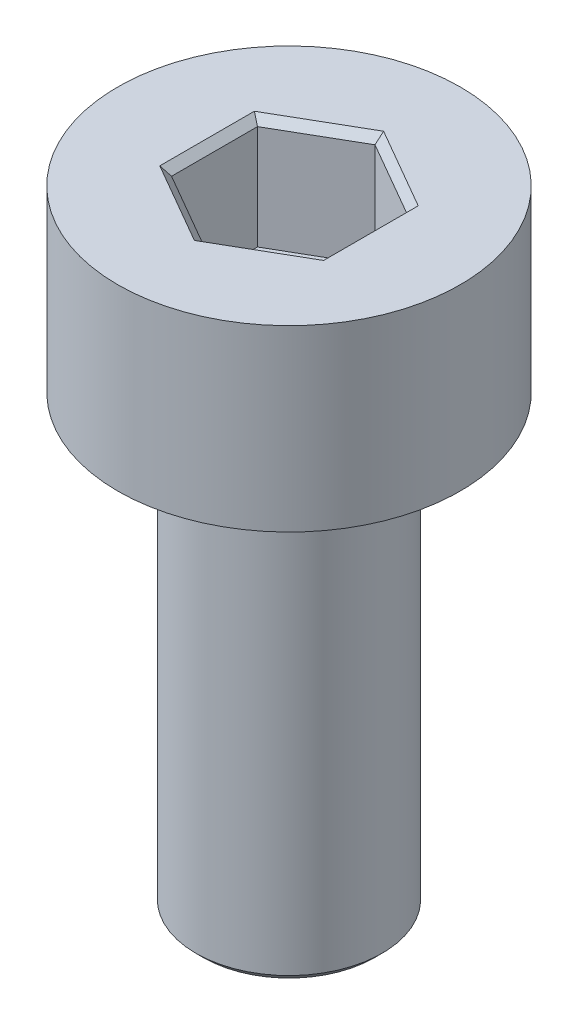
from build123d import *

# Parameters (mm, degrees)
SKETCH_1_R          = 2.3
EXTRUDE_1_DEPTH     = 2.4
CUT_EXTRUDE_1_DEPTH = 1.5
SKETCH_3_R          = 1.25
EXTRUDE_2_DEPTH     = 6
CHAMFER_1_SIZE      = 0.1


with BuildPart() as part:
    # 草图1 → 凸台-拉伸1 (new body)
    with BuildSketch(Plane(origin=(0, 0, 0), x_dir=(1, 0, 0), z_dir=(0, 1, 0))):
        Circle(SKETCH_1_R)
    extrude(amount=EXTRUDE_1_DEPTH)

    # 草图2 → 切除-拉伸1 (cut)
    with BuildSketch(Plane(origin=(0, 2.4, 0), x_dir=(1, 0, 0), z_dir=(0, 1, 0))):
        Polygon((0, -1.154700538), (1, -0.577350269), (1, 0.577350269), (0, 1.154700538), (-1, 0.577350269), (-1, -0.577350269), align=None)
    extrude(amount=-CUT_EXTRUDE_1_DEPTH, mode=Mode.SUBTRACT)

    # 草图3 → 凸台-拉伸2 (add)
    with BuildSketch(Plane.XZ):
        Circle(SKETCH_3_R)
    extrude(amount=EXTRUDE_2_DEPTH)

    # 倒角1
    chamfer_1_edges = [part.edges().sort_by_distance(p)[0] for p in [
        (-0.5, 2.4, 0.866025404),
        (0.5, 2.4, 0.866025404),
        (1, 2.4, 0),
        (0.5, 2.4, -0.866025404),
        (-0.5, 2.4, -0.866025404),
        (-1, 2.4, 0),
        (-1.25, -6, 0),
    ]]
    chamfer(chamfer_1_edges, length=CHAMFER_1_SIZE)


solid = part.part
